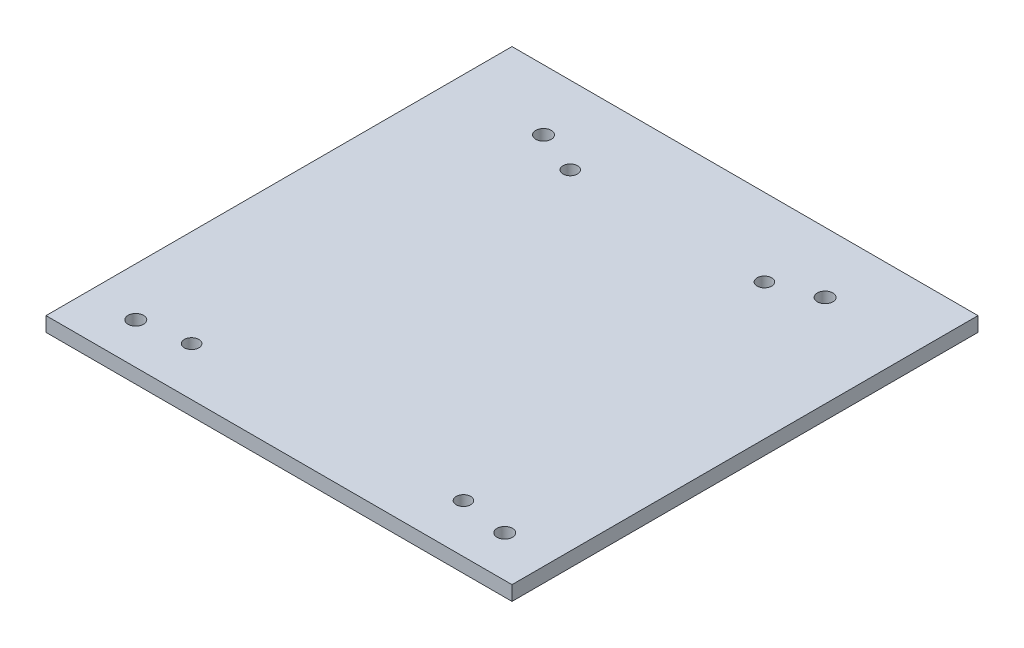
from build123d import *

# Parameters (mm, degrees)
SKETCH1_W           = 96
SKETCH1_H           = 96
SKETCH1_R           = 1.6
SKETCH1_R_2         = 1.5
BOSS_EXTRUDE1_DEPTH = 3


with BuildPart() as part:
    # Sketch1 → Boss-Extrude1 (new body)
    with BuildSketch(Plane(origin=(0, 0, 0), x_dir=(1, 0, 0), z_dir=(0, 1, 0))):
        with Locations((48, 48)):
            Rectangle(SKETCH1_W, SKETCH1_H)
        with Locations((19, 83.5)):
            Circle(SKETCH1_R, mode=Mode.SUBTRACT)
        with Locations((77, 83.5)):
            Circle(SKETCH1_R, mode=Mode.SUBTRACT)
        with Locations((10, 8.5)):
            Circle(SKETCH1_R, mode=Mode.SUBTRACT)
        with Locations((86, 8.5)):
            Circle(SKETCH1_R, mode=Mode.SUBTRACT)
        with Locations((28, 80)):
            Circle(SKETCH1_R_2, mode=Mode.SUBTRACT)
        with Locations((68, 80)):
            Circle(SKETCH1_R_2, mode=Mode.SUBTRACT)
        with Locations((20, 10)):
            Circle(SKETCH1_R_2, mode=Mode.SUBTRACT)
        with Locations((76, 10)):
            Circle(SKETCH1_R_2, mode=Mode.SUBTRACT)
    extrude(amount=BOSS_EXTRUDE1_DEPTH)


solid = part.part
